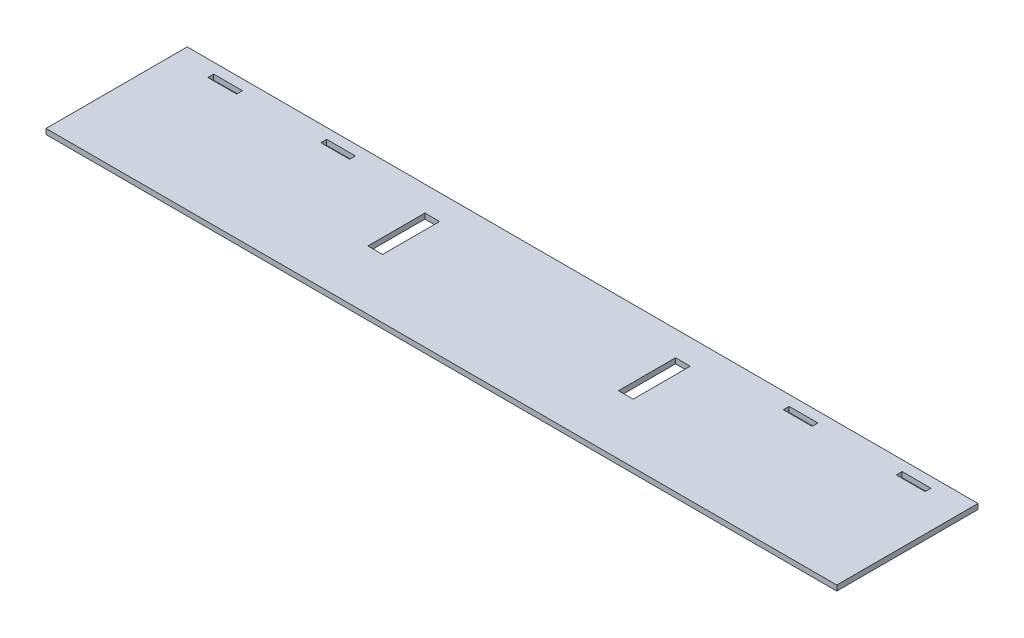
from build123d import *

# Parameters (mm, degrees)
SKETCH1_W           = 711.2
SKETCH1_H           = 127
BOSS_EXTRUDE1_DEPTH = 4.7625
SKETCH2_W           = 13.208
SKETCH2_H           = 51.308
CUT_EXTRUDE1_DEPTH  = 5.7625
SKETCH3_W           = 25.908
SKETCH3_H           = 5.2705
CUT_EXTRUDE2_DEPTH  = 5.7625


with BuildPart() as part:
    # Sketch1 → Boss-Extrude1 (new body)
    with BuildSketch(Plane(origin=(0, 0, 0), x_dir=(1, 0, 0), z_dir=(0, 1, 0))):
        with Locations((0, 63.5)):
            Rectangle(SKETCH1_W, SKETCH1_H)
    extrude(amount=BOSS_EXTRUDE1_DEPTH)

    # Sketch2 → Cut-Extrude1 (cut, through all)
    with BuildSketch(Plane(origin=(0, 0, 0), x_dir=(-1, 0, 0), z_dir=(0, -1, 0))):
        with Locations((-112.7125, 78.82990203)):
            Rectangle(SKETCH2_W, SKETCH2_H)
        with Locations((112.7125, 78.82990203)):
            Rectangle(SKETCH2_W, SKETCH2_H)
    extrude(amount=-CUT_EXTRUDE1_DEPTH, mode=Mode.SUBTRACT)

    # Sketch3 → Cut-Extrude2 (cut, through all)
    with BuildSketch(Plane.XZ):
        with Locations((-309.5625, -115.09375)):
            Rectangle(SKETCH3_W, SKETCH3_H)
        with Locations((-207.9625, -115.09375)):
            Rectangle(SKETCH3_W, SKETCH3_H)
        with Locations((207.9625, -115.09375)):
            Rectangle(SKETCH3_W, SKETCH3_H)
        with Locations((309.5625, -115.09375)):
            Rectangle(SKETCH3_W, SKETCH3_H)
    extrude(amount=-CUT_EXTRUDE2_DEPTH, mode=Mode.SUBTRACT)


solid = part.part
